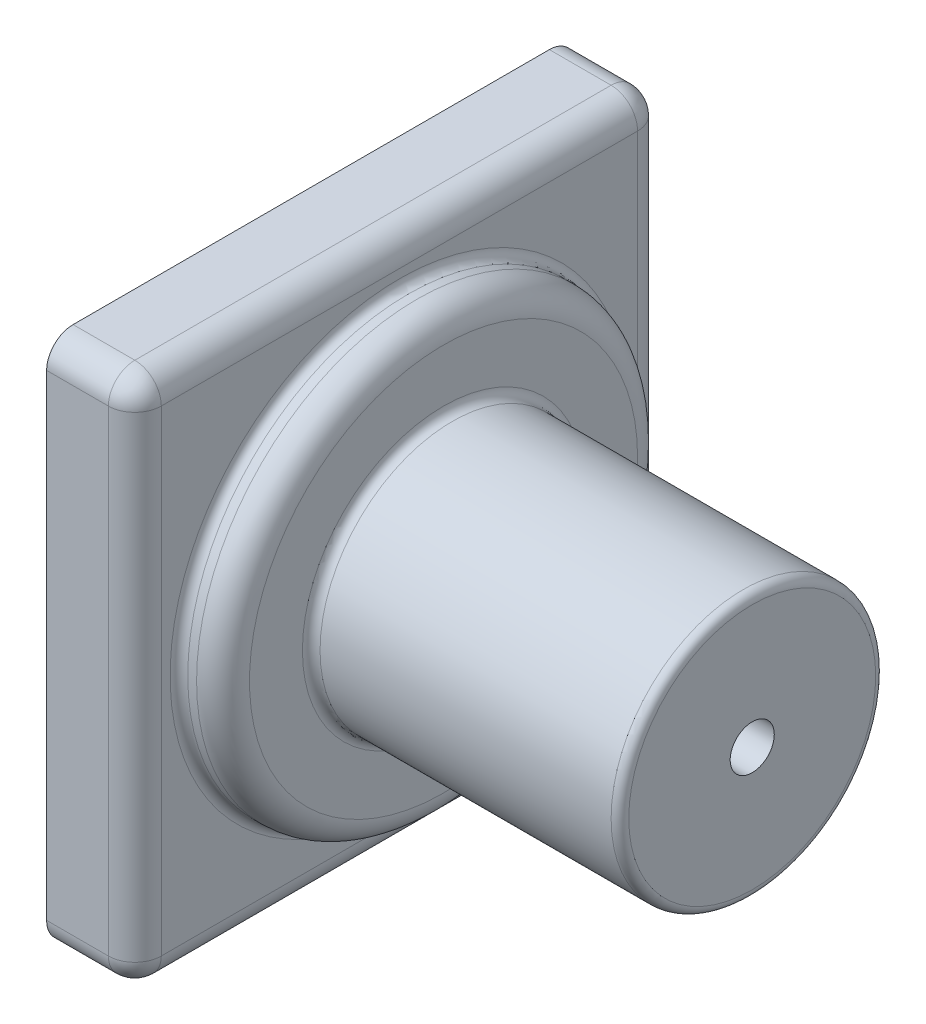
from build123d import *

# Parameters (mm, degrees)
SKETCH1_W           = 60
SKETCH1_H           = 60
BOSS_EXTRUDE1_DEPTH = 10
SKETCH2_R           = 25
BOSS_EXTRUDE2_DEPTH = 5
SKETCH3_R           = 15
BOSS_EXTRUDE3_DEPTH = 35
SKETCH4_R           = 2.5
CUT_EXTRUDE1_DEPTH  = 5
FILLET1_R           = 3
FILLET2_R           = 3
FILLET3_R           = 1


with BuildPart() as part:
    # Sketch1 → Boss-Extrude1 (new body)
    with BuildSketch(Plane(origin=(0, 0, 0), x_dir=(0, 0, -1), z_dir=(1, 0, 0))):
        Rectangle(SKETCH1_W, SKETCH1_H)
    extrude(amount=BOSS_EXTRUDE1_DEPTH)

    # Sketch2 → Boss-Extrude2 (add)
    with BuildSketch(Plane(origin=(10, 0, 0), x_dir=(0, 0, -1), z_dir=(1, 0, 0))):
        Circle(SKETCH2_R)
    extrude(amount=BOSS_EXTRUDE2_DEPTH)

    # Sketch3 → Boss-Extrude3 (add)
    with BuildSketch(Plane(origin=(15, 0, 0), x_dir=(0, 0, -1), z_dir=(1, 0, 0))):
        Circle(SKETCH3_R)
    extrude(amount=BOSS_EXTRUDE3_DEPTH)

    # Sketch4 → Cut-Extrude1 (cut)
    with BuildSketch(Plane(origin=(50, 0, 0), x_dir=(0, 0, -1), z_dir=(1, 0, 0))):
        Circle(SKETCH4_R)
    extrude(amount=-CUT_EXTRUDE1_DEPTH, mode=Mode.SUBTRACT)

    # Fillet1
    fillet1_edges = [part.edges().sort_by_distance(p)[0] for p in [
        (10, 0, 30),
        (10, -30, 0),
        (10, 0, -30),
        (5, -30, -30),
        (5, -30, 30),
        (5, 30, 30),
        (5, 30, -30),
        (10, 30, 0),
    ]]
    fillet(fillet1_edges, radius=FILLET1_R)

    # Fillet2
    fillet2_edges = [part.edges().sort_by_distance(p)[0] for p in [
        (15, 0, 25),
    ]]
    fillet(fillet2_edges, radius=FILLET2_R)

    # Fillet3
    fillet3_edges = [part.edges().sort_by_distance(p)[0] for p in [
        (10, 0, 25),
        (15, 0, 15),
        (50, 0, 15),
    ]]
    fillet(fillet3_edges, radius=FILLET3_R)


solid = part.part
